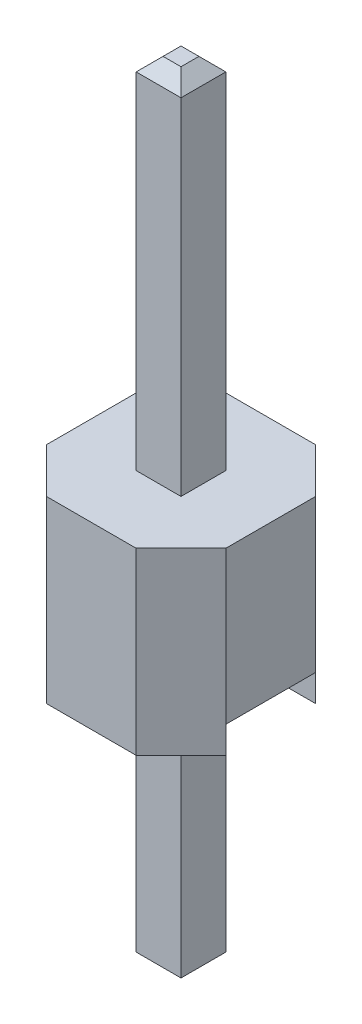
from build123d import *

# Parameters (mm, degrees)
BOSS_EXTRUDE1_DEPTH = 2.54
SKETCH2_W           = 1.27
SKETCH2_H           = 0.381
CUT_EXTRUDE1_DEPTH  = 2.54
SKETCH3_W           = 0.635
SKETCH3_H           = 0.635
BOSS_EXTRUDE2_DEPTH = 5.08
CHAMFER1_SIZE       = 0.1905
SKETCH4_W           = 0.635
SKETCH4_H           = 0.635
BOSS_EXTRUDE3_DEPTH = 3.937
CHAMFER2_SIZE       = 0.1905


with BuildPart() as part:
    # Sketch1 → Boss-Extrude1 (new body)
    with BuildSketch(Plane(origin=(0, 0, 0), x_dir=(1, 0, 0), z_dir=(0, 1, 0))):
        Polygon((0.635, 1.27), (1.27, 0.635), (1.27, -0.635), (0.635, -1.27), (-0.635, -1.27), (-1.27, -0.635), (-1.27, 0.635), (-0.635, 1.27), align=None)
    extrude(amount=BOSS_EXTRUDE1_DEPTH)

    # Sketch2 → Cut-Extrude1 (cut)
    with BuildSketch(Plane(origin=(1.27, 0, 0), x_dir=(0, 0, -1), z_dir=(1, 0, 0))):
        with Locations((0, 0.1905)):
            Rectangle(SKETCH2_W, SKETCH2_H)
    extrude(amount=-CUT_EXTRUDE1_DEPTH, mode=Mode.SUBTRACT)

    # Sketch3 → Boss-Extrude2 (add)
    with BuildSketch(Plane(origin=(0, 2.54, 0), x_dir=(1, 0, 0), z_dir=(0, 1, 0))):
        Rectangle(SKETCH3_W, SKETCH3_H)
    extrude(amount=BOSS_EXTRUDE2_DEPTH)

    # Chamfer1
    chamfer1_edges = [part.edges().sort_by_distance(p)[0] for p in [
        (0.3175, 7.62, 0),
        (0, 7.62, -0.3175),
        (-0.3175, 7.62, 0),
        (0, 7.62, 0.3175),
    ]]
    chamfer(chamfer1_edges, length=CHAMFER1_SIZE)

    # Sketch4 → Boss-Extrude3 (add)
    with BuildSketch(Plane.XZ.offset(-0.381)):
        Rectangle(SKETCH4_W, SKETCH4_H)
    extrude(amount=BOSS_EXTRUDE3_DEPTH)

    # Chamfer2
    chamfer2_edges = [part.edges().sort_by_distance(p)[0] for p in [
        (0.3175, -3.556, 0),
        (0, -3.556, 0.3175),
        (-0.3175, -3.556, 0),
        (0, -3.556, -0.3175),
    ]]
    chamfer(chamfer2_edges, length=CHAMFER2_SIZE)


solid = part.part
